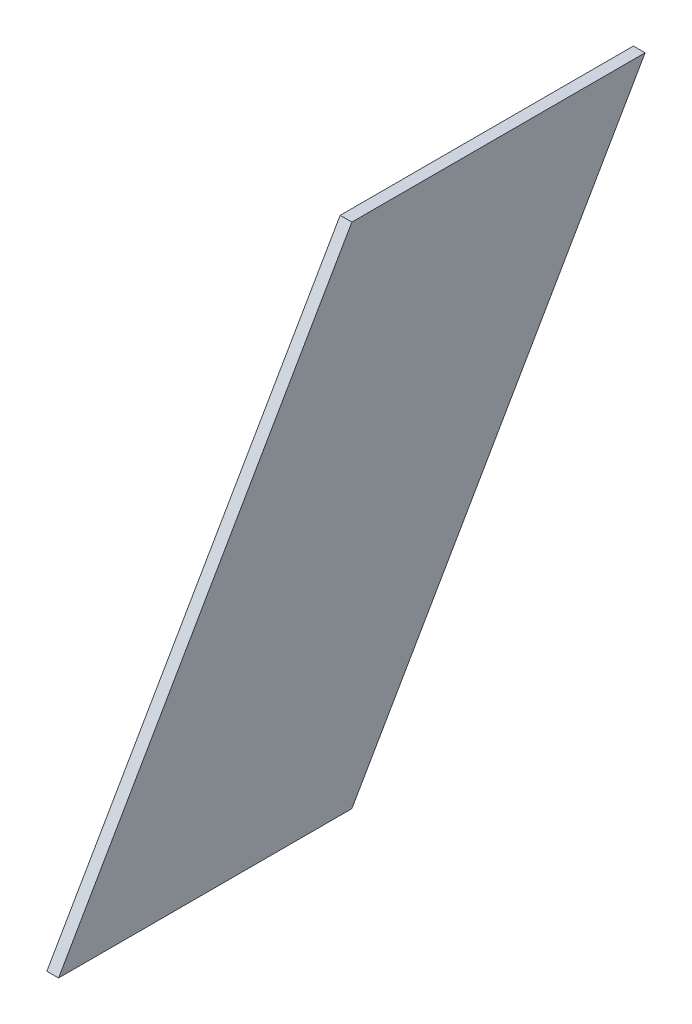
from build123d import *

# Parameters (mm, degrees)
BOSS_EXTRUDE1_DEPTH = 2
SKETCH2_R           = 0.5
CUT_EXTRUDE2_DEPTH  = 2


with BuildPart() as part:
    # Sketch1 → Boss-Extrude1 (new body)
    with BuildSketch(Plane(origin=(0, 0, 0), x_dir=(0, 0, -1), z_dir=(1, 0, 0))):
        Polygon((0, 0), (50, 0), (100, 86.602540378), (50, 86.602540378), align=None)
    extrude(amount=BOSS_EXTRUDE1_DEPTH)

    # Sketch2 → Cut-Extrude2 (cut)
    with BuildSketch(Plane.XZ):
        with Locations((1, -25)):
            Circle(SKETCH2_R)
    extrude(amount=-CUT_EXTRUDE2_DEPTH, mode=Mode.SUBTRACT)


solid = part.part
